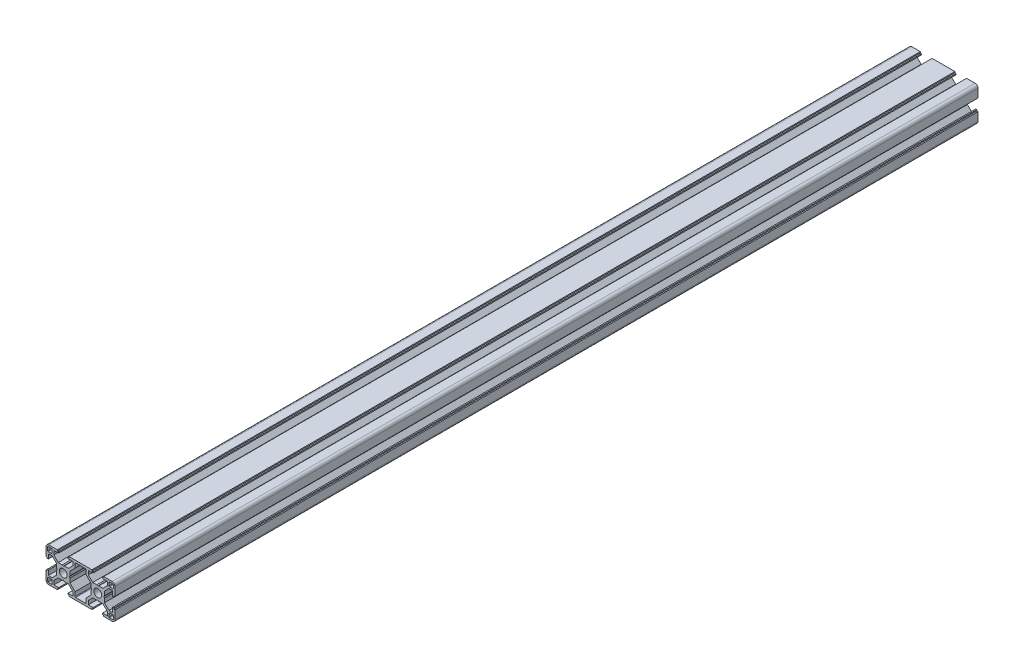
from build123d import *

# Parameters (mm, degrees)
ESQUISSE1_R      = 3.4
EXTRUSION1_DEPTH = 750


with BuildPart() as part:
    # Esquisse1 → Extrusion1 (new body)
    with BuildSketch(Plane.XY):
        with BuildLine():
            Line((16.03204155, 18.693478261), (15.03204155, 18.693478261))
            Line((15.03204155, 18.693478261), (15.03204155, 19.693478261))
            Line((15.03204155, 19.693478261), (-4.76795845, 19.693478261))
            Line((-4.76795845, 19.693478261), (-4.76795845, 18.693478261))
            Line((-4.76795845, 18.693478261), (-5.76795845, 18.693478261))
            Line((-5.76795845, 18.693478261), (-5.76795845, 17.693478261))
            Line((-5.76795845, 17.693478261), (-1.61795845, 17.693478261))
            Line((-1.61795845, 17.693478261), (-1.61795845, 14.33992487))
            Line((-1.61795845, 14.33992487), (-5.464405059, 10.493478261))
            Line((-5.464405059, 10.493478261), (-9.001933046, 10.493478261))
            Line((-9.001933046, 10.493478261), (-9.86795845, 9.993478261))
            Line((-9.86795845, 9.993478261), (-10.733983853, 10.493478261))
            Line((-10.733983853, 10.493478261), (-14.27151184, 10.493478261))
            Line((-14.27151184, 10.493478261), (-18.11795845, 14.33992487))
            Line((-18.11795845, 14.33992487), (-18.11795845, 17.693478261))
            Line((-18.11795845, 17.693478261), (-13.96795845, 17.693478261))
            Line((-13.96795845, 17.693478261), (-13.96795845, 18.693478261))
            Line((-13.96795845, 18.693478261), (-14.96795845, 18.693478261))
            Line((-14.96795845, 18.693478261), (-14.96795845, 19.693478261))
            Line((-14.96795845, 19.693478261), (-22.36795845, 19.693478261))
            ThreePointArc((-22.36795845, 19.693478261), (-24.135725403, 18.961245214), (-24.86795845, 17.193478261))
            Line((-24.86795845, 17.193478261), (-24.86795845, 9.793478261))
            Line((-24.86795845, 9.793478261), (-23.86795845, 9.793478261))
            Line((-23.86795845, 9.793478261), (-23.86795845, 8.793478261))
            Line((-23.86795845, 8.793478261), (-22.86795845, 8.793478261))
            Line((-22.86795845, 8.793478261), (-22.86795845, 12.943478261))
            Line((-22.86795845, 12.943478261), (-19.514405059, 12.943478261))
            Line((-19.514405059, 12.943478261), (-15.66795845, 9.097031651))
            Line((-15.66795845, 9.097031651), (-15.66795845, 5.559503665))
            Line((-15.66795845, 5.559503665), (-15.16795845, 4.693478261))
            Line((-15.16795845, 4.693478261), (-15.66795845, 3.827452857))
            Line((-15.66795845, 3.827452857), (-15.66795845, 0.28992487))
            Line((-15.66795845, 0.28992487), (-19.514405059, -3.556521739))
            Line((-19.514405059, -3.556521739), (-22.86795845, -3.556521739))
            Line((-22.86795845, -3.556521739), (-22.86795845, 0.593478261))
            Line((-22.86795845, 0.593478261), (-23.86795845, 0.593478261))
            Line((-23.86795845, 0.593478261), (-23.86795845, -0.406521739))
            Line((-23.86795845, -0.406521739), (-24.86795845, -0.406521739))
            Line((-24.86795845, -0.406521739), (-24.86795845, -7.806521739))
            ThreePointArc((-24.86795845, -7.806521739), (-24.135725403, -9.574288692), (-22.36795845, -10.306521739))
            Line((-22.36795845, -10.306521739), (-14.96795845, -10.306521739))
            Line((-14.96795845, -10.306521739), (-14.96795845, -9.306521739))
            Line((-14.96795845, -9.306521739), (-13.96795845, -9.306521739))
            Line((-13.96795845, -9.306521739), (-13.96795845, -8.306521739))
            Line((-13.96795845, -8.306521739), (-18.11795845, -8.306521739))
            Line((-18.11795845, -8.306521739), (-18.11795845, -4.952968349))
            Line((-18.11795845, -4.952968349), (-14.27151184, -1.106521739))
            Line((-14.27151184, -1.106521739), (-10.733983853, -1.106521739))
            Line((-10.733983853, -1.106521739), (-9.86795845, -0.606521739))
            Line((-9.86795845, -0.606521739), (-9.001933046, -1.106521739))
            Line((-9.001933046, -1.106521739), (-5.464405059, -1.106521739))
            Line((-5.464405059, -1.106521739), (-1.61795845, -4.952968349))
            Line((-1.61795845, -4.952968349), (-1.61795845, -8.306521739))
            Line((-1.61795845, -8.306521739), (-5.76795845, -8.306521739))
            Line((-5.76795845, -8.306521739), (-5.76795845, -9.306521739))
            Line((-5.76795845, -9.306521739), (-4.76795845, -9.306521739))
            Line((-4.76795845, -9.306521739), (-4.76795845, -10.306521739))
            Line((-4.76795845, -10.306521739), (15.03204155, -10.306521739))
            Line((15.03204155, -10.306521739), (15.03204155, -9.306521739))
            Line((15.03204155, -9.306521739), (16.03204155, -9.306521739))
            Line((16.03204155, -9.306521739), (16.03204155, -8.306521739))
            Line((16.03204155, -8.306521739), (11.88204155, -8.306521739))
            Line((11.88204155, -8.306521739), (11.88204155, -4.952968349))
            Line((11.88204155, -4.952968349), (15.72848816, -1.106521739))
            Line((15.72848816, -1.106521739), (19.266016147, -1.106521739))
            Line((19.266016147, -1.106521739), (20.13204155, -0.606521739))
            Line((20.13204155, -0.606521739), (20.998066954, -1.106521739))
            Line((20.998066954, -1.106521739), (24.535594941, -1.106521739))
            Line((24.535594941, -1.106521739), (28.38204155, -4.952968349))
            Line((28.38204155, -4.952968349), (28.38204155, -8.306521739))
            Line((28.38204155, -8.306521739), (24.23204155, -8.306521739))
            Line((24.23204155, -8.306521739), (24.23204155, -9.306521739))
            Line((24.23204155, -9.306521739), (25.23204155, -9.306521739))
            Line((25.23204155, -9.306521739), (25.23204155, -10.306521739))
            Line((25.23204155, -10.306521739), (32.63204155, -10.306521739))
            ThreePointArc((32.63204155, -10.306521739), (34.399808503, -9.574288692), (35.13204155, -7.806521739))
            Line((35.13204155, -7.806521739), (35.13204155, -0.406521739))
            Line((35.13204155, -0.406521739), (34.13204155, -0.406521739))
            Line((34.13204155, -0.406521739), (34.13204155, 0.593478261))
            Line((34.13204155, 0.593478261), (33.13204155, 0.593478261))
            Line((33.13204155, 0.593478261), (33.13204155, -3.556521739))
            Line((33.13204155, -3.556521739), (29.77848816, -3.556521739))
            Line((29.77848816, -3.556521739), (25.93204155, 0.28992487))
            Line((25.93204155, 0.28992487), (25.93204155, 3.827452857))
            Line((25.93204155, 3.827452857), (25.43204155, 4.693478261))
            Line((25.43204155, 4.693478261), (25.93204155, 5.559503665))
            Line((25.93204155, 5.559503665), (25.93204155, 9.097031651))
            Line((25.93204155, 9.097031651), (29.77848816, 12.943478261))
            Line((29.77848816, 12.943478261), (33.13204155, 12.943478261))
            Line((33.13204155, 12.943478261), (33.13204155, 8.793478261))
            Line((33.13204155, 8.793478261), (34.13204155, 8.793478261))
            Line((34.13204155, 8.793478261), (34.13204155, 9.793478261))
            Line((34.13204155, 9.793478261), (35.13204155, 9.793478261))
            Line((35.13204155, 9.793478261), (35.13204155, 17.193478261))
            ThreePointArc((35.13204155, 17.193478261), (34.399808503, 18.961245214), (32.63204155, 19.693478261))
            Line((32.63204155, 19.693478261), (25.23204155, 19.693478261))
            Line((25.23204155, 19.693478261), (25.23204155, 18.693478261))
            Line((25.23204155, 18.693478261), (24.23204155, 18.693478261))
            Line((24.23204155, 18.693478261), (24.23204155, 17.693478261))
            Line((24.23204155, 17.693478261), (28.38204155, 17.693478261))
            Line((28.38204155, 17.693478261), (28.38204155, 14.33992487))
            Line((28.38204155, 14.33992487), (24.535594941, 10.493478261))
            Line((24.535594941, 10.493478261), (20.998066954, 10.493478261))
            Line((20.998066954, 10.493478261), (20.13204155, 9.993478261))
            Line((20.13204155, 9.993478261), (19.266016147, 10.493478261))
            Line((19.266016147, 10.493478261), (15.72848816, 10.493478261))
            Line((15.72848816, 10.493478261), (11.88204155, 14.33992487))
            Line((11.88204155, 14.33992487), (11.88204155, 17.693478261))
            Line((11.88204155, 17.693478261), (16.03204155, 17.693478261))
            Line((16.03204155, 17.693478261), (16.03204155, 18.693478261))
        make_face()
        with Locations((-9.86795845, 4.693478261)):
            Circle(ESQUISSE1_R, mode=Mode.SUBTRACT)
        with Locations((20.13204155, 4.693478261)):
            Circle(ESQUISSE1_R, mode=Mode.SUBTRACT)
        with BuildLine():
            Line((-23.36795845, 14.943478261), (-23.36795845, 17.693478261))
            ThreePointArc((-23.36795845, 17.693478261), (-23.22151184, 18.047031651), (-22.86795845, 18.193478261))
            Line((-22.86795845, 18.193478261), (-20.11795845, 18.193478261))
            ThreePointArc((-20.11795845, 18.193478261), (-19.764405059, 18.047031651), (-19.61795845, 17.693478261))
            Line((-19.61795845, 17.693478261), (-19.61795845, 14.943478261))
            ThreePointArc((-19.61795845, 14.943478261), (-19.764405059, 14.58992487), (-20.11795845, 14.443478261))
            Line((-20.11795845, 14.443478261), (-22.86795845, 14.443478261))
            ThreePointArc((-22.86795845, 14.443478261), (-23.22151184, 14.58992487), (-23.36795845, 14.943478261))
        make_face(mode=Mode.SUBTRACT)
        with BuildLine():
            Line((-19.61795845, -5.556521739), (-19.61795845, -8.306521739))
            ThreePointArc((-19.61795845, -8.306521739), (-19.764405059, -8.66007513), (-20.11795845, -8.806521739))
            Line((-20.11795845, -8.806521739), (-22.86795845, -8.806521739))
            ThreePointArc((-22.86795845, -8.806521739), (-23.22151184, -8.66007513), (-23.36795845, -8.306521739))
            Line((-23.36795845, -8.306521739), (-23.36795845, -5.556521739))
            ThreePointArc((-23.36795845, -5.556521739), (-23.22151184, -5.202968349), (-22.86795845, -5.056521739))
            Line((-22.86795845, -5.056521739), (-20.11795845, -5.056521739))
            ThreePointArc((-20.11795845, -5.056521739), (-19.764405059, -5.202968349), (-19.61795845, -5.556521739))
        make_face(mode=Mode.SUBTRACT)
        with BuildLine():
            Line((14.33204155, 0.325458776), (9.88204155, -4.124541224))
            Line((9.88204155, -4.124541224), (9.88204155, -7.806521739))
            ThreePointArc((9.88204155, -7.806521739), (9.735594941, -8.16007513), (9.38204155, -8.306521739))
            Line((9.38204155, -8.306521739), (0.88204155, -8.306521739))
            ThreePointArc((0.88204155, -8.306521739), (0.52848816, -8.16007513), (0.38204155, -7.806521739))
            Line((0.38204155, -7.806521739), (0.38204155, -4.124541224))
            Line((0.38204155, -4.124541224), (-4.06795845, 0.325458776))
            Line((-4.06795845, 0.325458776), (-4.06795845, 3.827452857))
            Line((-4.06795845, 3.827452857), (-4.56795845, 4.693478261))
            Line((-4.56795845, 4.693478261), (-4.06795845, 5.559503665))
            Line((-4.06795845, 5.559503665), (-4.06795845, 9.061497746))
            Line((-4.06795845, 9.061497746), (0.38204155, 13.511497746))
            Line((0.38204155, 13.511497746), (0.38204155, 17.193478261))
            ThreePointArc((0.38204155, 17.193478261), (0.52848816, 17.547031651), (0.88204155, 17.693478261))
            Line((0.88204155, 17.693478261), (9.38204155, 17.693478261))
            ThreePointArc((9.38204155, 17.693478261), (9.735594941, 17.547031651), (9.88204155, 17.193478261))
            Line((9.88204155, 17.193478261), (9.88204155, 13.511497746))
            Line((9.88204155, 13.511497746), (14.33204155, 9.061497746))
            Line((14.33204155, 9.061497746), (14.33204155, 5.559503665))
            Line((14.33204155, 5.559503665), (14.83204155, 4.693478261))
            Line((14.83204155, 4.693478261), (14.33204155, 3.827452857))
            Line((14.33204155, 3.827452857), (14.33204155, 0.325458776))
        make_face(mode=Mode.SUBTRACT)
        with BuildLine():
            Line((29.88204155, 14.943478261), (29.88204155, 17.693478261))
            ThreePointArc((29.88204155, 17.693478261), (30.02848816, 18.047031651), (30.38204155, 18.193478261))
            Line((30.38204155, 18.193478261), (33.13204155, 18.193478261))
            ThreePointArc((33.13204155, 18.193478261), (33.485594941, 18.047031651), (33.63204155, 17.693478261))
            Line((33.63204155, 17.693478261), (33.63204155, 14.943478261))
            ThreePointArc((33.63204155, 14.943478261), (33.485594941, 14.58992487), (33.13204155, 14.443478261))
            Line((33.13204155, 14.443478261), (30.38204155, 14.443478261))
            ThreePointArc((30.38204155, 14.443478261), (30.02848816, 14.58992487), (29.88204155, 14.943478261))
        make_face(mode=Mode.SUBTRACT)
        with BuildLine():
            Line((29.88204155, -8.306521739), (29.88204155, -5.556521739))
            ThreePointArc((29.88204155, -5.556521739), (30.02848816, -5.202968349), (30.38204155, -5.056521739))
            Line((30.38204155, -5.056521739), (33.13204155, -5.056521739))
            ThreePointArc((33.13204155, -5.056521739), (33.485594941, -5.202968349), (33.63204155, -5.556521739))
            Line((33.63204155, -5.556521739), (33.63204155, -8.306521739))
            ThreePointArc((33.63204155, -8.306521739), (33.485594941, -8.66007513), (33.13204155, -8.806521739))
            Line((33.13204155, -8.806521739), (30.38204155, -8.806521739))
            ThreePointArc((30.38204155, -8.806521739), (30.02848816, -8.66007513), (29.88204155, -8.306521739))
        make_face(mode=Mode.SUBTRACT)
    extrude(amount=EXTRUSION1_DEPTH)


solid = part.part
